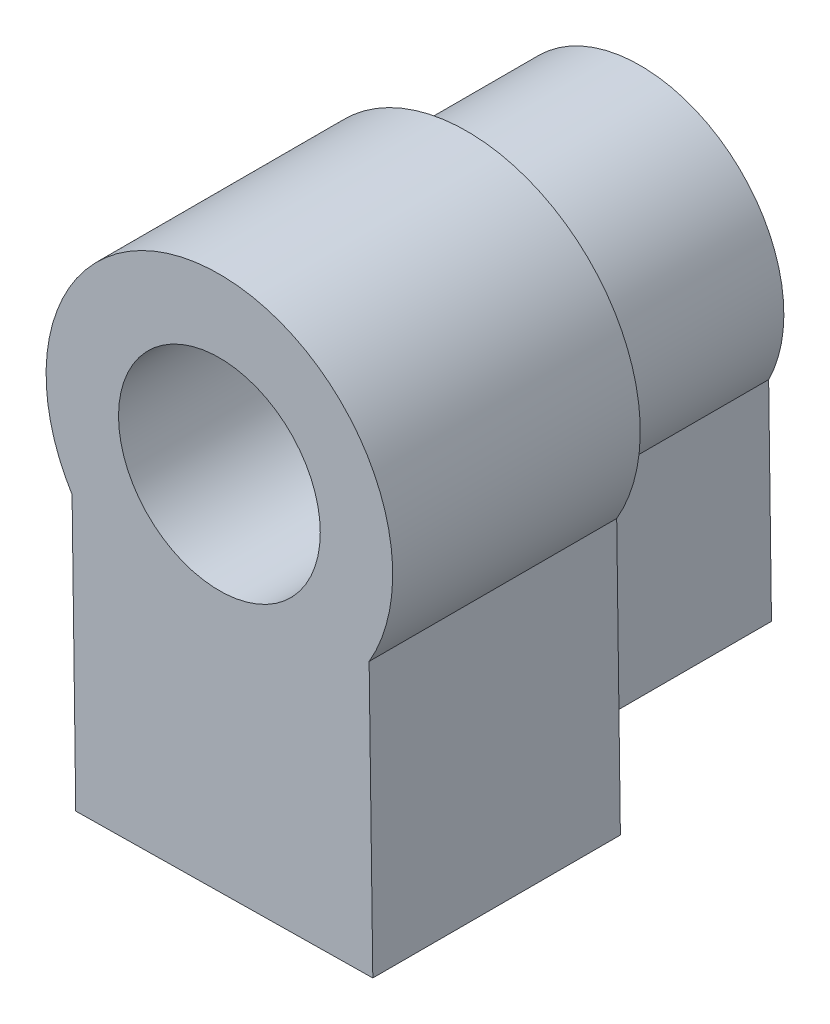
from build123d import *

# Parameters (mm, degrees)
BOSS_EXTRUDE1_DEPTH = 7
BOSS_EXTRUDE3_DEPTH = 10
SKETCH6_R           = 1.35
CUT_EXTRUDE3_DEPTH  = 8.5


with BuildPart() as part:
    # Sketch1 → Boss-Extrude1 (new body)
    with BuildSketch(Plane.XY):
        with BuildLine():
            ThreePointArc((5.050452833, -4.633288902), (-0.057176836, -7.835700867), (-5.249547167, -4.77259565))
            Line((-5.249547167, -4.77259565), (-5.135937781, -13.17259565))
            Line((-5.135937781, -13.17259565), (5.164062219, -13.033288902))
            Line((5.164062219, -13.033288902), (5.050452833, -4.633288902))
        make_face()
        with BuildLine():
            ThreePointArc((5.664385761, -2.036231273), (-1.546144107, 3.589638037), (-5.249547167, -4.77259565))
            Line((-5.249547167, -4.77259565), (5.050452833, -4.633288902))
            ThreePointArc((5.050452833, -4.633288902), (5.508816158, -3.370549635), (5.664385761, -2.036231273))
        make_face()
        with BuildLine():
            Line((5.050452833, -4.633288902), (-5.249547167, -4.77259565))
            ThreePointArc((-5.249547167, -4.77259565), (-0.057176836, -7.835700867), (5.050452833, -4.633288902))
        make_face()
    extrude(amount=BOSS_EXTRUDE1_DEPTH)

    # Sketch2 → Boss-Extrude3 (add)
    with BuildSketch(Plane.XY.offset(7)):
        with BuildLine():
            Line((5.063146119, -5.571799449), (5.912597424, -5.560310683))
            ThreePointArc((5.912597424, -5.560310683), (6.622250869, -3.861405013), (6.864385761, -2.036231273))
            ThreePointArc((6.864385761, -2.036231273), (-2.052012342, 4.696332749), (-6.086305185, -5.722594964))
            Line((-6.086305185, -5.722594964), (-5.236853881, -5.711106197))
            Line((-5.236853881, -5.711106197), (-5.249547167, -4.77259565))
            ThreePointArc((-5.249547167, -4.77259565), (-0.214051642, 3.763238321), (5.050452833, -4.633288902))
            Line((5.050452833, -4.633288902), (5.063146119, -5.571799449))
        make_face()
        with BuildLine():
            Line((1.811820806, -5.615773387), (5.063146119, -5.571799449))
            Line((5.063146119, -5.571799449), (5.050452833, -4.633288902))
            ThreePointArc((5.050452833, -4.633288902), (-0.214051642, 3.763238321), (-5.249547167, -4.77259565))
            Line((-5.249547167, -4.77259565), (-5.236853881, -5.711106197))
            Line((-5.236853881, -5.711106197), (-1.985528568, -5.66713226))
            ThreePointArc((-1.985528568, -5.66713226), (-2.264842281, 1.438248968), (3.939385761, -2.036231273))
            ThreePointArc((3.939385761, -2.036231273), (3.367343284, -4.118276805), (1.811820806, -5.615773387))
        make_face()
        with BuildLine():
            Line((5.078495254, -6.706676883), (5.063146119, -5.571799449))
            Line((5.063146119, -5.571799449), (1.811820806, -5.615773387))
            ThreePointArc((1.811820806, -5.615773387), (-0.080505202, -6.110858617), (-1.985528568, -5.66713226))
            Line((-1.985528568, -5.66713226), (-5.236853881, -5.711106197))
            Line((-5.236853881, -5.711106197), (-5.221504746, -6.845983631))
            ThreePointArc((-5.221504746, -6.845983631), (-0.040948408, -9.035591128), (5.078495254, -6.706676883))
        make_face()
        with BuildLine():
            Line((5.164062219, -13.033288902), (5.078495254, -6.706676883))
            ThreePointArc((5.078495254, -6.706676883), (-0.040948408, -9.035591128), (-5.221504746, -6.845983631))
            Line((-5.221504746, -6.845983631), (-5.135937781, -13.17259565))
            Line((-5.135937781, -13.17259565), (5.164062219, -13.033288902))
        make_face()
        with BuildLine():
            Line((6.06137162, -16.560310683), (5.912597424, -5.560310683))
            ThreePointArc((5.912597424, -5.560310683), (5.524642674, -6.154664432), (5.078495254, -6.706676883))
            Line((5.078495254, -6.706676883), (5.164062219, -13.033288902))
            Line((5.164062219, -13.033288902), (-5.135937781, -13.17259565))
            Line((-5.135937781, -13.17259565), (-5.221504746, -6.845983631))
            ThreePointArc((-5.221504746, -6.845983631), (-5.6824181, -6.30623911), (-6.086305185, -5.722594964))
            Line((-6.086305185, -5.722594964), (-5.937530989, -16.722594964))
            Line((-5.937530989, -16.722594964), (6.06137162, -16.560310683))
        make_face()
        with BuildLine():
            ThreePointArc((5.078495254, -6.706676883), (5.524642674, -6.154664432), (5.912597424, -5.560310683))
            Line((5.912597424, -5.560310683), (5.063146119, -5.571799449))
            Line((5.063146119, -5.571799449), (5.078495254, -6.706676883))
        make_face()
        with BuildLine():
            Line((-5.236853881, -5.711106197), (-6.086305185, -5.722594964))
            ThreePointArc((-6.086305185, -5.722594964), (-5.6824181, -6.30623911), (-5.221504746, -6.845983631))
            Line((-5.221504746, -6.845983631), (-5.236853881, -5.711106197))
        make_face()
    extrude(amount=BOSS_EXTRUDE3_DEPTH)

    # Sketch6 → Cut-Extrude3 (cut)
    with BuildSketch(Plane(origin=(0.225044595, -16.639246579, 0), x_dir=(-0.999908551, -0.01352369, 0), z_dir=(0.01352369, -0.999908551, 0))):
        with Locations((0.241163233, -13)):
            Circle(SKETCH6_R)
    extrude(amount=-CUT_EXTRUDE3_DEPTH, mode=Mode.SUBTRACT)


solid = part.part
